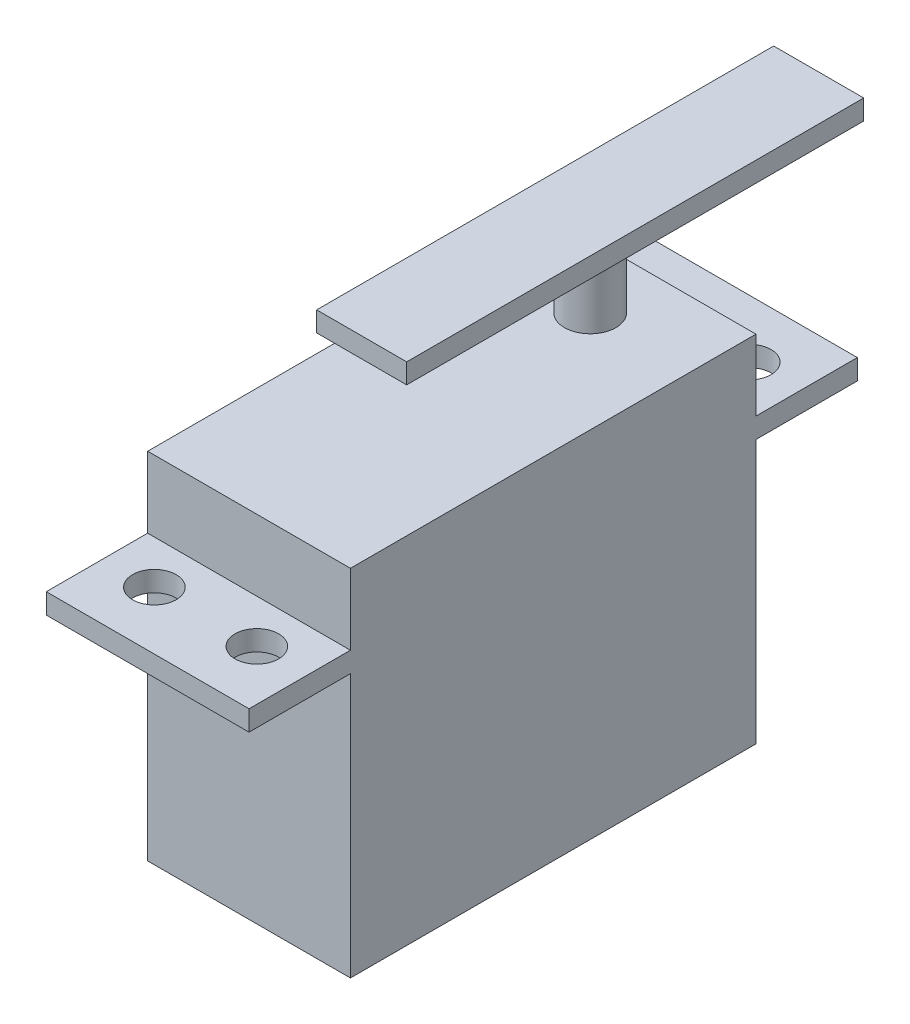
from build123d import *

# Parameters (mm, degrees)
BOSS_EXTRUDE1_DEPTH      = 9
BOSS_EXTRUDE1_DEPTH_BACK = 26
SKETCH1_W                = 20
SKETCH1_H                = 40
SKETCH2_R                = 2.54
BOSS_EXTRUDE2_DEPTH      = 7.33
SKETCH3_W                = 8.88
SKETCH3_H                = 45.08
BOSS_EXTRUDE3_DEPTH      = 1.97
SKETCH6_W                = 20
SKETCH6_H                = 10
BOSS_EXTRUDE5_DEPTH      = 2
SKETCH8_R                = 2.15
CUT_EXTRUDE1_DEPTH       = 5.159375


with BuildPart() as part:
    # Sketch1 → Boss-Extrude1 (new, two sides: drawn at the far end of the back side and taken through both)
    with BuildSketch(Plane(origin=(0, 0, 0), x_dir=(1, 0, 0), z_dir=(0, 1, 0)).offset(-BOSS_EXTRUDE1_DEPTH_BACK)):
        Rectangle(SKETCH1_W, SKETCH1_H)
    extrude(amount=BOSS_EXTRUDE1_DEPTH + BOSS_EXTRUDE1_DEPTH_BACK)

    # Sketch2 → Boss-Extrude2 (add)
    with BuildSketch(Plane(origin=(0, 9, 0), x_dir=(1, 0, 0), z_dir=(0, 1, 0))):
        with Locations((0, 13.65)):
            Circle(SKETCH2_R)
    extrude(amount=BOSS_EXTRUDE2_DEPTH)

    # Sketch3 → Boss-Extrude3 (add)
    with BuildSketch(Plane(origin=(0, 16.33, 0), x_dir=(1, 0, 0), z_dir=(0, 1, 0))):
        with Locations((0, 13.65)):
            Rectangle(SKETCH3_W, SKETCH3_H)
    extrude(amount=BOSS_EXTRUDE3_DEPTH)

    # Sketch6 → Boss-Extrude5 (add)
    with BuildSketch(Plane(origin=(0, 0, 0), x_dir=(1, 0, 0), z_dir=(0, 1, 0))):
        with Locations((0, -25)):
            Rectangle(SKETCH6_W, SKETCH6_H)
        with Locations((0, 25)):
            Rectangle(SKETCH6_W, SKETCH6_H)
    extrude(amount=BOSS_EXTRUDE5_DEPTH)

    # Sketch8 → Cut-Extrude1 (cut)
    with BuildSketch(Plane(origin=(0, 0, 0), x_dir=(1, 0, 0), z_dir=(0, 1, 0))):
        with Locations((5.055, -24.285)):
            Circle(SKETCH8_R)
        with Locations((-5.055, -24.285)):
            Circle(SKETCH8_R)
        with Locations((5.055, 24.285)):
            Circle(SKETCH8_R)
        with Locations((-5.055, 24.285)):
            Circle(SKETCH8_R)
    extrude(amount=CUT_EXTRUDE1_DEPTH, mode=Mode.SUBTRACT)


solid = part.part
